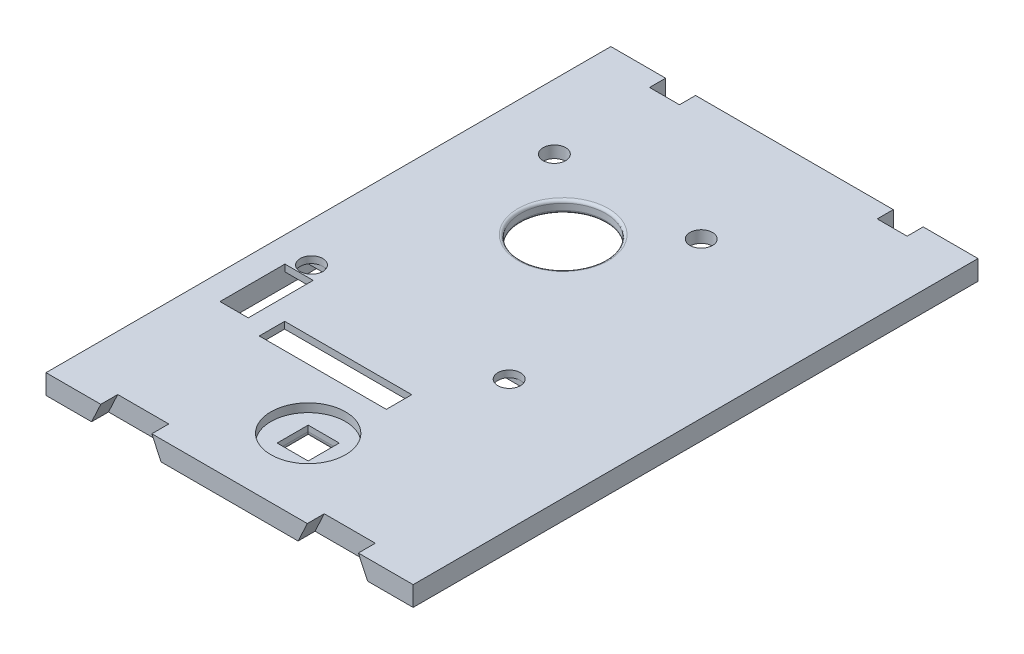
from build123d import *

# Parameters (mm, degrees)
SKETCH1_W                = 65
SKETCH1_H                = 100
BOSS_EXTRUDE1_DEPTH      = 3.5
SKETCH2_W                = 40
SKETCH2_H                = 61
CUT_EXTRUDE1_DEPTH       = 1.4
SKETCH3_R                = 2
CUT_EXTRUDE3_DEPTH       = 3.5
SKETCH4_R                = 2
CUT_EXTRUDE5_DEPTH       = 3.5
SKETCH6_R                = 2
CUT_EXTRUDE6_DEPTH       = 3.5
SKETCH7_R                = 2
CUT_EXTRUDE7_DEPTH       = 3.5
SKETCH9_W                = 19
SKETCH9_H                = 6
CUT_EXTRUDE9_DEPTH       = 2.3
SKETCH10_W               = 22.5
SKETCH10_H               = 4.5
CUT_EXTRUDE10_DEPTH      = 3.5
CUT_EXTRUDE11_DEPTH      = 2.3
CUT_EXTRUDE15_DEPTH      = 2.5
SKETCH18_W               = 2.7
SKETCH18_H               = 50.5
CUT_EXTRUDE18_DEPTH      = 2.5
SKETCH8_W                = 5
SKETCH8_H                = 11.5
CUT_EXTRUDE25_DEPTH      = 3.5
SKETCH20_R               = 7.5
CUT_EXTRUDE27_DEPTH      = 2.4
CUT_EXTRUDE27_DEPTH_BACK = 3.1
SKETCH21_W               = 5.3
SKETCH21_H               = 2.85
CUT_EXTRUDE28_DEPTH      = 3.5
CUT_EXTRUDE30_DEPTH      = 3
FILLET2_R                = 0.5
SKETCH27_R               = 6.6
CUT_EXTRUDE32_DEPTH      = 1.5
SKETCH28_W               = 5.5
SKETCH28_H               = 5.5
CUT_EXTRUDE33_DEPTH      = 3
FILLET4_R                = 1


with BuildPart() as part:
    # Sketch1 → Boss-Extrude1 (new body)
    with BuildSketch(Plane(origin=(0, 0, 0), x_dir=(1, 0, 0), z_dir=(0, 1, 0))):
        Rectangle(SKETCH1_W, SKETCH1_H)
    extrude(amount=BOSS_EXTRUDE1_DEPTH)

    # Sketch2 → Cut-Extrude1 (cut)
    with BuildSketch(Plane(origin=(0, 0, 0), x_dir=(1, 0, 0), z_dir=(0, 1, 0))):
        with Locations((-8, 5)):
            Rectangle(SKETCH2_W, SKETCH2_H)
    extrude(amount=CUT_EXTRUDE1_DEPTH, mode=Mode.SUBTRACT)

    # Sketch3 → Cut-Extrude3 (cut)
    with BuildSketch(Plane(origin=(0, 0, 0), x_dir=(1, 0, 0), z_dir=(0, 1, 0))):
        with Locations((-21, 28.5)):
            Circle(SKETCH3_R)
    extrude(amount=CUT_EXTRUDE3_DEPTH, mode=Mode.SUBTRACT)

    # Sketch4 → Cut-Extrude5 (cut)
    with BuildSketch(Plane(origin=(0, 0, 0), x_dir=(1, 0, 0), z_dir=(0, 1, 0))):
        with Locations((5, 28.5)):
            Circle(SKETCH4_R)
    extrude(amount=CUT_EXTRUDE5_DEPTH, mode=Mode.SUBTRACT)

    # Sketch6 → Cut-Extrude6 (cut)
    with BuildSketch(Plane(origin=(0, 0, 0), x_dir=(1, 0, 0), z_dir=(0, 1, 0))):
        with Locations((-25.5, -10)):
            Circle(SKETCH6_R)
    extrude(amount=CUT_EXTRUDE6_DEPTH, mode=Mode.SUBTRACT)

    # Sketch7 → Cut-Extrude7 (cut)
    with BuildSketch(Plane(origin=(0, 0, 0), x_dir=(1, 0, 0), z_dir=(0, 1, 0))):
        with Locations((9.5, -10)):
            Circle(SKETCH7_R)
    extrude(amount=CUT_EXTRUDE7_DEPTH, mode=Mode.SUBTRACT)

    # Sketch9 → Cut-Extrude9 (cut)
    with BuildSketch(Plane(origin=(0, 0, 0), x_dir=(1, 0, 0), z_dir=(0, 1, 0))):
        with Locations((-8, -0.5)):
            Rectangle(SKETCH9_W, SKETCH9_H)
    extrude(amount=CUT_EXTRUDE9_DEPTH, mode=Mode.SUBTRACT)

    # Sketch10 → Cut-Extrude10 (cut)
    with BuildSketch(Plane(origin=(0, 0, 0), x_dir=(1, 0, 0), z_dir=(0, 1, 0))):
        with Locations((-8, -23.25)):
            Rectangle(SKETCH10_W, SKETCH10_H)
    extrude(amount=CUT_EXTRUDE10_DEPTH, mode=Mode.SUBTRACT)

    # Sketch11 → Cut-Extrude11 (cut)
    with BuildSketch(Plane(origin=(0, 0, 0), x_dir=(1, 0, 0), z_dir=(0, 1, 0))):
        Polygon((-28, -25.5), (3.25, -25.5), (12, -25.5), (12, -21), (12, -8), (-28, -8), align=None)
    extrude(amount=CUT_EXTRUDE11_DEPTH, mode=Mode.SUBTRACT)

    # Sketch12 → Cut-Extrude15 (cut)
    with BuildSketch(Plane(origin=(0, 0, 0), x_dir=(1, 0, 0), z_dir=(0, 1, 0))):
        Polygon((28, -20.8), (28, 25), (30.7, 25), (30.7, -25.5), (12, -25.5), (12, -20.8), align=None)
    extrude(amount=CUT_EXTRUDE15_DEPTH, mode=Mode.SUBTRACT)

    # Sketch18 → Cut-Extrude18 (cut)
    with BuildSketch(Plane(origin=(0, 0, 0), x_dir=(1, 0, 0), z_dir=(0, 1, 0))):
        with Locations((-30.15, -0.25)):
            Rectangle(SKETCH18_W, SKETCH18_H)
    extrude(amount=CUT_EXTRUDE18_DEPTH, mode=Mode.SUBTRACT)

    # Sketch8 → Cut-Extrude25 (cut)
    with BuildSketch(Plane(origin=(0, 0, 0), x_dir=(1, 0, 0), z_dir=(0, 1, 0))):
        with Locations((-25.5, -17.95)):
            Rectangle(SKETCH8_W, SKETCH8_H)
    extrude(amount=CUT_EXTRUDE25_DEPTH, mode=Mode.SUBTRACT)

    # Sketch20 → Cut-Extrude27 (cut, two sides)
    with BuildSketch(Plane.XZ.offset(-1.4)) as cut_extrude27_sk:
        with Locations((-7.887877966, -16.952018436)):
            Circle(SKETCH20_R)
    extrude(amount=CUT_EXTRUDE27_DEPTH, mode=Mode.SUBTRACT)
    extrude(cut_extrude27_sk.sketch, amount=-CUT_EXTRUDE27_DEPTH_BACK, mode=Mode.SUBTRACT)

    # Sketch21 → Cut-Extrude28 (cut)
    with BuildSketch(Plane.XZ):
        with Locations((-20.15, -48.575)):
            Rectangle(SKETCH21_W, SKETCH21_H)
        with Locations((20.15, -48.575)):
            Rectangle(SKETCH21_W, SKETCH21_H)
    extrude(amount=-CUT_EXTRUDE28_DEPTH, mode=Mode.SUBTRACT)

    # Sketch25 → Cut-Extrude30 (cut)
    with BuildSketch(Plane.XY.offset(50)):
        Polygon((22.8, 3.5), (13.764153607, 3.5), (12.132076804, 0), (24.432076804, 0), align=None)
        Polygon((-22.8, 3.5), (-24.432076804, 0), (-12.132076804, 0), (-13.764153607, 3.5), align=None)
    extrude(amount=-CUT_EXTRUDE30_DEPTH, mode=Mode.SUBTRACT)

    # Fillet2
    fillet2_edges = [part.edges().sort_by_distance(p)[0] for p in [
        (-15.387877966, 1.4, -16.952018436),
        (-15.387877966, 3.5, -16.952018436),
    ]]
    fillet(fillet2_edges, radius=FILLET2_R)

    # Sketch27 → Cut-Extrude32 (cut)
    with BuildSketch(Plane(origin=(0, 3.5, 0), x_dir=(1, 0, 0), z_dir=(0, 1, 0))):
        with Locations((0, -36.08346839)):
            Circle(SKETCH27_R)
    extrude(amount=-CUT_EXTRUDE32_DEPTH, mode=Mode.SUBTRACT)

    # Sketch28 → Cut-Extrude33 (cut, through all)
    with BuildSketch(Plane(origin=(0, 2, 0), x_dir=(1, 0, 0), z_dir=(0, 1, 0))):
        with Locations((0, -36.08346839)):
            Rectangle(SKETCH28_W, SKETCH28_H)
    extrude(amount=-CUT_EXTRUDE33_DEPTH, mode=Mode.SUBTRACT)

    # Fillet4
    fillet4_edges = [part.edges().sort_by_distance(p)[0] for p in [
        (2.75, 0, 36.08346839),
        (0, 0, 38.83346839),
        (-2.75, 0, 36.08346839),
        (0, 0, 33.33346839),
    ]]
    fillet(fillet4_edges, radius=FILLET4_R)


solid = part.part
